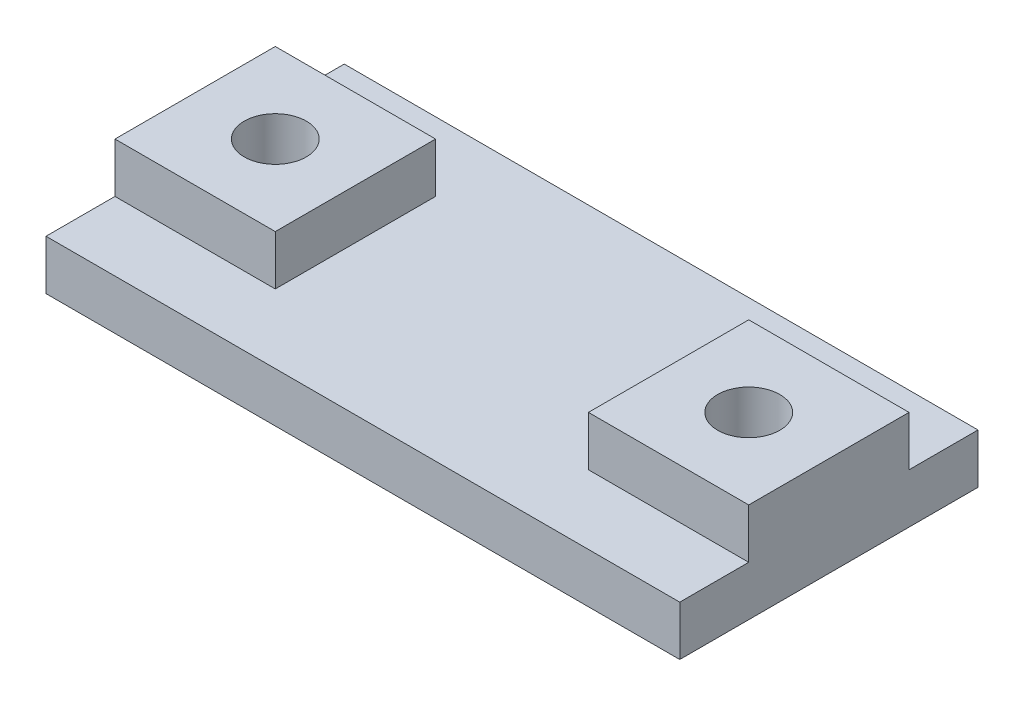
from build123d import *

# Parameters (mm, degrees)
SKETCH2_W             = 25.5
SKETCH2_H             = 12
BOSS_EXTRUDE1_DEPTH   = 2
SKETCH3_W             = 6.45
SKETCH3_H             = 6.45
BOSS_EXTRUDE2_DEPTH   = 2
M3X0_5_TAPPED_HOLE1_D = 2.5


with BuildPart() as part:
    # Sketch2 → Boss-Extrude1 (new body)
    with BuildSketch(Plane(origin=(0, 0, 0), x_dir=(1, 0, 0), z_dir=(0, 1, 0))):
        Rectangle(SKETCH2_W, SKETCH2_H)
    extrude(amount=BOSS_EXTRUDE1_DEPTH)

    # Sketch3 → Boss-Extrude2 (add)
    with BuildSketch(Plane(origin=(0, 2, 0), x_dir=(1, 0, 0), z_dir=(0, 1, 0))):
        with Locations((-9.525, 0)):
            Rectangle(SKETCH3_W, SKETCH3_H)
        with Locations((9.525, 0)):
            Rectangle(SKETCH3_W, SKETCH3_H)
    extrude(amount=BOSS_EXTRUDE2_DEPTH)

    # M3x0.5 Tapped Hole1 (through all)
    with Locations(Plane(origin=(0, 4, 0), x_dir=(1, 0, 0), z_dir=(0, 1, 0))):
        with Locations((-9.525, 0), (9.525, 0)):
            Hole(M3X0_5_TAPPED_HOLE1_D / 2)


solid = part.part
